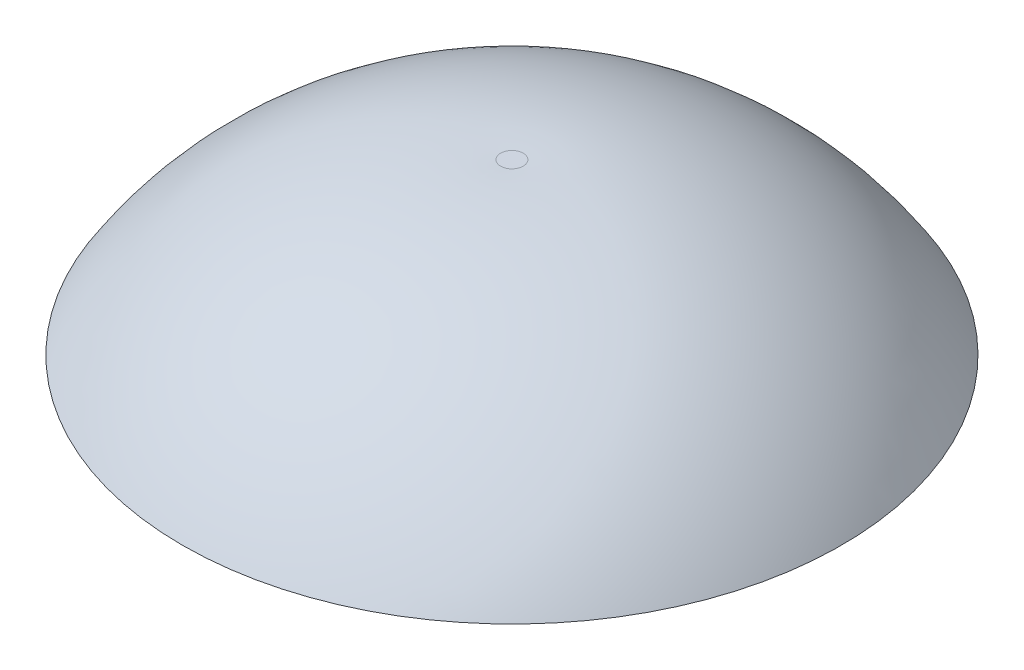
from build123d import *
from build123d.topology import SkipClean

# Parameters (mm, degrees)
REVOLVE5_ANGLE = 90
SKETCH1_24_W   = 2.54
SKETCH1_24_H   = 28.448


with BuildPart() as part:
    # Sketch1 → Revolve4 (revolve)
    with BuildSketch(Plane.XY):
        Polygon((9.525, 101.6), (9.525, 104.902), (2.54, 104.902), (0, 104.902), (0, 101.6), (6.35, 101.6), align=None)
    revolve(axis=Axis((0, 133.35, 0), (0, -1, 0)))

    # Sketch1_21 → Revolve5 (revolve, symmetric)
    with SkipClean():  # the faces are left unmerged after this step: merging them gives an invalid solid
        with BuildSketch(Plane.XY) as revolve5_sk:
            Polygon((9.525, 95.25), (9.525, 101.6), (6.35, 101.6), (6.35, 97.79), (3.937, 97.79), (3.937, 95.25), align=None)
            Polygon((-6.35, 97.79), (-6.35, 101.6), (-9.525, 101.6), (-9.525, 95.25), (-3.937, 95.25), (-3.937, 97.79), align=None)
        revolve(axis=Axis((0, 133.35, 0), (0, -1, 0)), revolution_arc=REVOLVE5_ANGLE / 2)
        revolve(revolve5_sk.sketch, axis=Axis((0, 133.35, 0), (0, 1, 0)), revolution_arc=REVOLVE5_ANGLE / 2)

    # Sketch1_24 → Revolve7 (revolve)
    with SkipClean():  # the faces are left unmerged after this step: merging them gives an invalid solid
        with BuildSketch(Plane.XY):
            with Locations((1.27, 119.126)):
                Rectangle(SKETCH1_24_W, SKETCH1_24_H)
        revolve(axis=Axis((0, 133.35, 0), (0, -1, 0)))

    # Sketch1_32 → Revolve8 (revolve)
    with SkipClean():  # the faces are left unmerged after this step: merging them gives an invalid solid
        with BuildSketch(Plane.XY):
            with BuildLine():
                ThreePointArc((7.619929338, 133.38281581), (5.07970677, 133.406330996), (2.54, 133.35))
                Line((2.54, 133.35), (0, 133.35))
                Line((0, 133.35), (0, 130.866278235))
                Line((0, 130.866278235), (5.08, 130.866278235))
                ThreePointArc((5.08, 130.866278235), (6.350063158, 130.864440752), (7.619929338, 130.841997813))
                Line((7.619929338, 130.841997813), (7.619929338, 133.38281581))
            make_face()
        revolve(axis=Axis((0, 133.35, 0), (0, -1, 0)))

    # Sketch1_36 → Revolve9 (revolve)
    with SkipClean():  # the faces are left unmerged after this step: merging them gives an invalid solid
        with BuildSketch(Plane.XY):
            with BuildLine():
                Line((7.619929338, 133.38281581), (7.619929338, 130.841997813))
                ThreePointArc((7.619929338, 130.841997813), (44.514359536, 120.511244071), (72.087103792, 93.909228608))
                Line((72.087103792, 93.909228608), (74.244401193, 95.25))
                ThreePointArc((74.244401193, 95.25), (45.748561471, 122.731465818), (7.619929338, 133.38281581))
            make_face()
        revolve(axis=Axis((0, 133.35, 0), (0, -1, 0)))


solid = part.part
